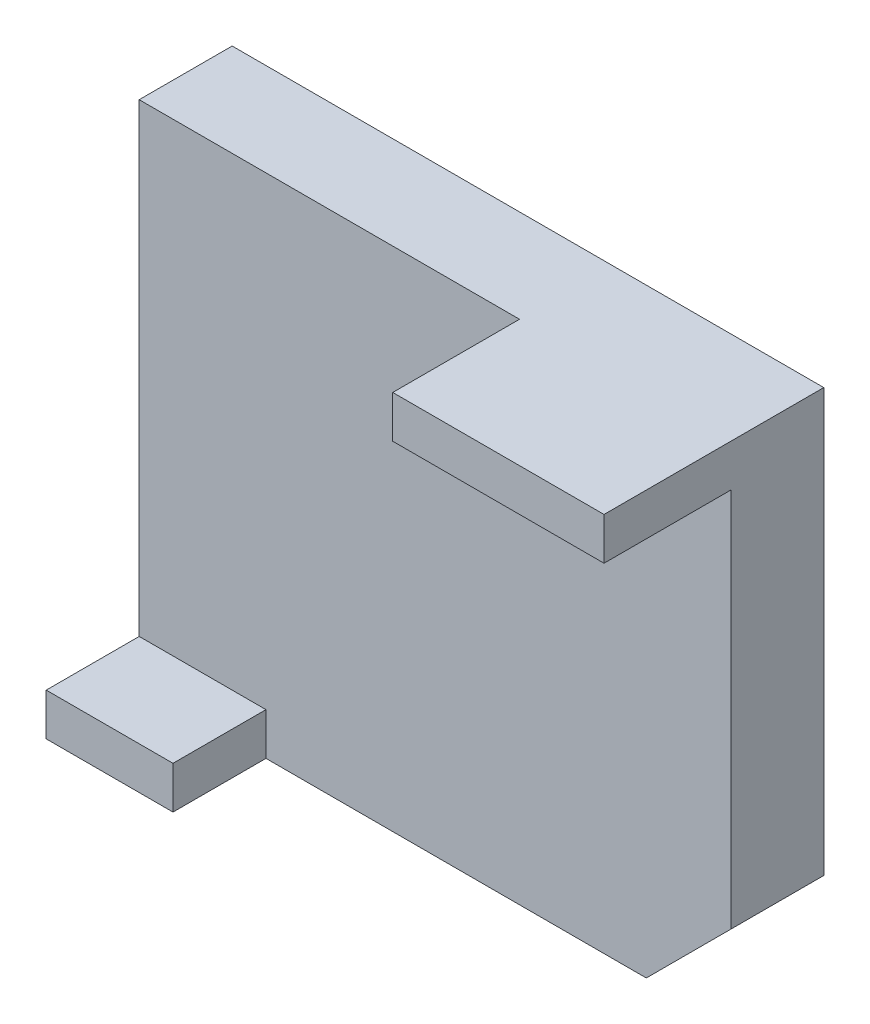
from build123d import *

# Parameters (mm, degrees)
BOSS_EXTRUDE1_DEPTH = 22
SKETCH1_3_W         = 30
SKETCH1_3_H         = 10
BOSS_EXTRUDE2_DEPTH = 44
SKETCH1_4_W         = 30
SKETCH1_4_H         = 10
BOSS_EXTRUDE3_DEPTH = 52
SKETCH1_5_W         = 20
SKETCH1_5_H         = 10
BOSS_EXTRUDE4_DEPTH = 52


with BuildPart() as part:
    # Sketch1 → Boss-Extrude1 (new body)
    with BuildSketch(Plane.XY):
        Polygon((90, 0), (0, 0), (0, -110), (30, -110), (30, -120), (120, -120), (140, -100), (140, -10), (110, -10), (90, -10), align=None)
    extrude(amount=BOSS_EXTRUDE1_DEPTH)

    # Sketch1_3 → Boss-Extrude2 (add)
    with BuildSketch(Plane.XY):
        with Locations((15, -115)):
            Rectangle(SKETCH1_3_W, SKETCH1_3_H)
    extrude(amount=BOSS_EXTRUDE2_DEPTH)

    # Sketch1_4 → Boss-Extrude3 (add)
    with BuildSketch(Plane.XY):
        with Locations((125, -5)):
            Rectangle(SKETCH1_4_W, SKETCH1_4_H)
    extrude(amount=BOSS_EXTRUDE3_DEPTH)

    # Sketch1_5 → Boss-Extrude4 (add)
    with BuildSketch(Plane.XY):
        with Locations((100, -5)):
            Rectangle(SKETCH1_5_W, SKETCH1_5_H)
    extrude(amount=BOSS_EXTRUDE4_DEPTH)


solid = part.part
